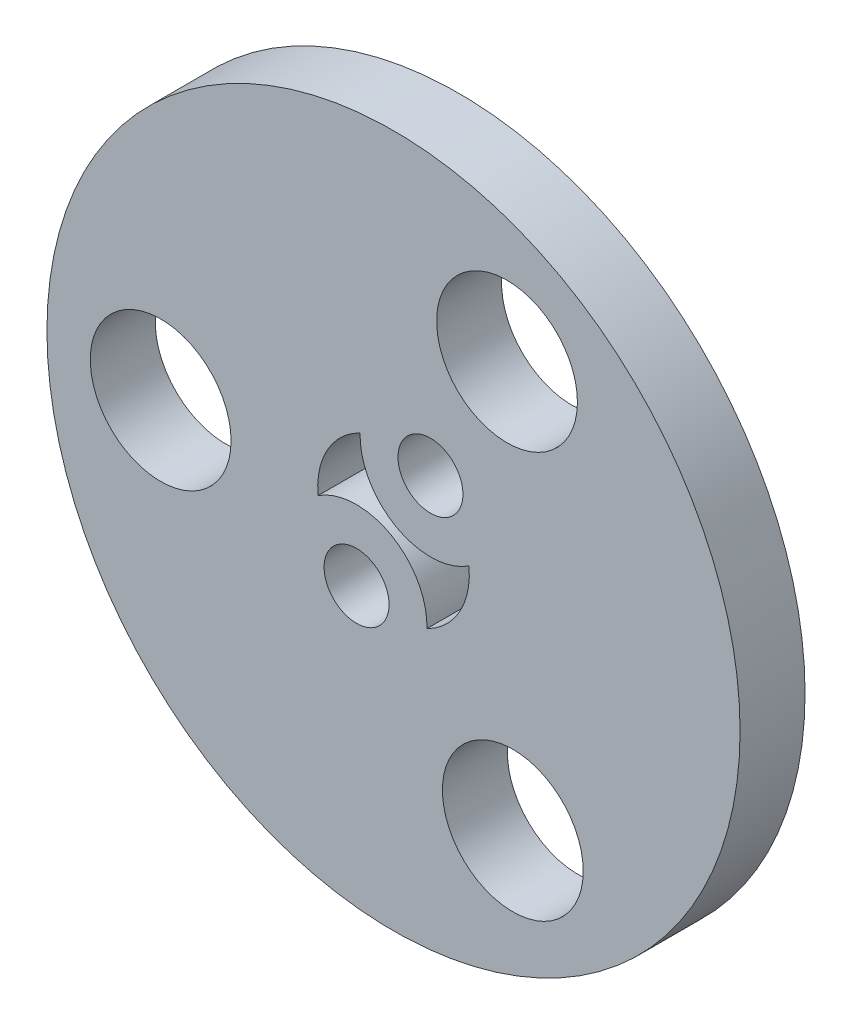
from build123d import *

# Parameters (mm, degrees)
ESQUISSE1_R        = 16
ESQUISSE1_R_2      = 3.25
ESQUISSE1_R_3      = 1.5
BOSS_EXTRU_1_DEPTH = 3


with BuildPart() as part:
    # Esquisse1 → Boss.-Extru.1 (new body)
    with BuildSketch(Plane.XY):
        Circle(ESQUISSE1_R)
        with Locations((5.508433282, -9.231449657)):
            Circle(ESQUISSE1_R_2, mode=Mode.SUBTRACT)
        with Locations((-10.748886558, -0.154718329)):
            Circle(ESQUISSE1_R_2, mode=Mode.SUBTRACT)
        with Locations((5.240453276, 9.386167986)):
            Circle(ESQUISSE1_R_2, mode=Mode.SUBTRACT)
        with Locations((1.70619409, 3.05596167)):
            Circle(ESQUISSE1_R_3, mode=Mode.SUBTRACT)
        with Locations((-1.70619409, -3.05596167)):
            Circle(ESQUISSE1_R_3, mode=Mode.SUBTRACT)
        with BuildLine():
            ThreePointArc((-1.54267531, 3.141679947), (0.121871006, 0.218282976), (3.483906341, 0.335256035))
            ThreePointArc((3.483906341, 0.335256035), (3.05596167, -1.70619409), (1.54267531, -3.141679947))
            ThreePointArc((1.54267531, -3.141679947), (-0.121871006, -0.218282976), (-3.483906341, -0.335256035))
            ThreePointArc((-3.483906341, -0.335256035), (-3.05596167, 1.70619409), (-1.54267531, 3.141679947))
        make_face(mode=Mode.SUBTRACT)
    extrude(amount=BOSS_EXTRU_1_DEPTH)


solid = part.part
